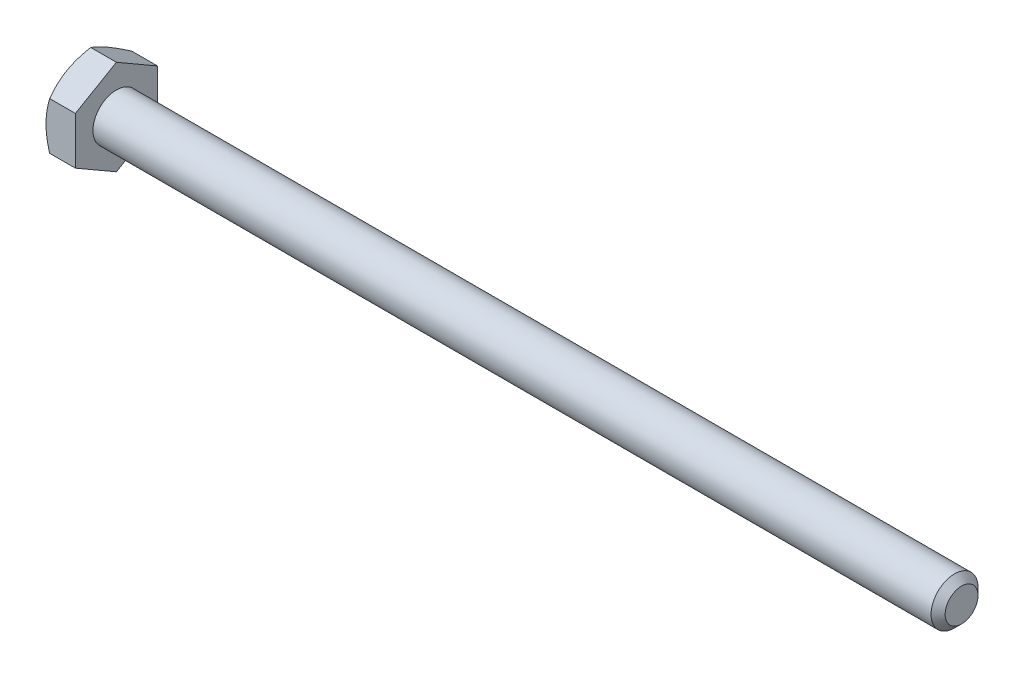
from build123d import *

# Parameters (mm, degrees)
SKETCH5_R           = 3.175
BOSS_EXTRUDE3_DEPTH = 114.3
CHAMFER1_SIZE       = 0.9525
BOSS_EXTRUDE4_DEPTH = 3.96875
SKETCH8_OUTSIDE_W   = 450.168
SKETCH8_OUTSIDE_H   = 451.888
SKETCH8_OUTSIDE_R   = 5.55625
CUT_EXTRUDE3_DEPTH  = 119.26875
CUT_EXTRUDE3_TAPER  = 60
CUT_EXTRUDE4_DEPTH  = 0.254
CIRPATTERN1_COUNT   = 3


with BuildPart() as part:
    # Sketch5 → Boss-Extrude3 (new body)
    with BuildSketch(Plane(origin=(59.134375, 0, 0), x_dir=(0, 0, -1), z_dir=(1, 0, 0))):
        Circle(SKETCH5_R)
    extrude(amount=-BOSS_EXTRUDE3_DEPTH)

    # Chamfer1
    chamfer1_edges = [part.edges().sort_by_distance(p)[0] for p in [
        (59.134375, 0, 3.175),
    ]]
    chamfer(chamfer1_edges, length=CHAMFER1_SIZE)

    # Sketch11 → Revolve1 (revolve)
    with BuildSketch(Plane.XY):
        Polygon((-55.165625, 3.175), (-55.165625, 0), (43.259375, 0), (40.084375, 3.175), align=None)
    revolve(axis=Axis((-55.165625, 0, 0), (1, 0, 0)))

    # Sketch6 → Boss-Extrude4 (add)
    with BuildSketch(Plane.ZY.offset(55.165625)):
        Polygon((5.55625, 3.207902433), (0, 6.415804866), (-5.55625, 3.207902433), (-5.55625, -3.207902433), (0, -6.415804866), (5.55625, -3.207902433), align=None)
    extrude(amount=BOSS_EXTRUDE4_DEPTH)

    # Sketch8 outside → Cut-Extrude3 (cut, through all)
    with BuildSketch(Plane.ZY.offset(59.134375)):
        Rectangle(SKETCH8_OUTSIDE_W, SKETCH8_OUTSIDE_H)
        Circle(SKETCH8_OUTSIDE_R, mode=Mode.SUBTRACT)
    extrude(amount=-CUT_EXTRUDE3_DEPTH, taper=CUT_EXTRUDE3_TAPER, mode=Mode.SUBTRACT)

    # Sketch12 → Cut-Extrude4 (cut)
    with BuildSketch(Plane.ZY.offset(59.134375)):
        with BuildLine():
            Line((0.1666875, 4.2783125), (0.1666875, 2.3891875))
            ThreePointArc((0.1666875, 2.3891875), (0, 2.2225), (-0.1666875, 2.3891875))
            Line((-0.1666875, 2.3891875), (-0.1666875, 4.2783125))
            ThreePointArc((-0.1666875, 4.2783125), (0, 4.445), (0.1666875, 4.2783125))
        make_face()
    cut_extrude4 = extrude(amount=-CUT_EXTRUDE4_DEPTH, mode=Mode.SUBTRACT)

    # CirPattern1: Cut-Extrude4 ×3 about axis
    cirpattern1_axis = Axis((0, 0, 0), (1, 0, 0))
    for i in range(1, CIRPATTERN1_COUNT):
        add(cut_extrude4.rotate(cirpattern1_axis, i * 360 / CIRPATTERN1_COUNT), mode=Mode.SUBTRACT)


solid = part.part
